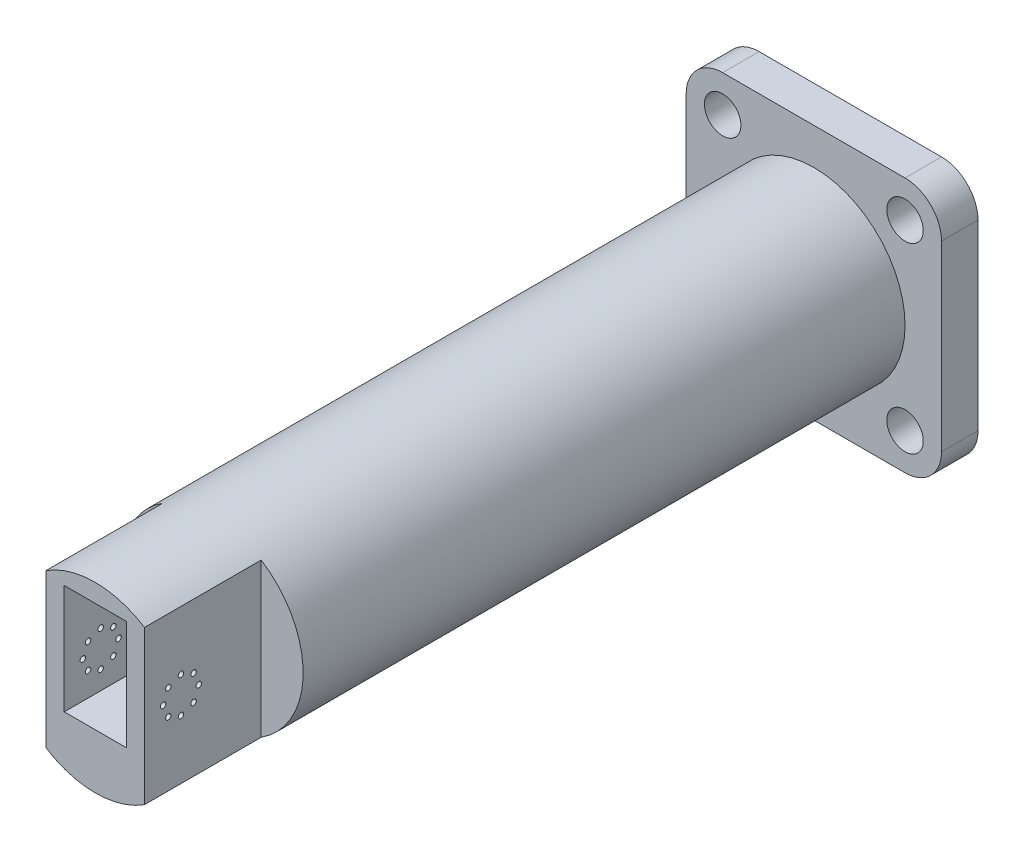
from build123d import *

# Parameters (mm, degrees)
CROQUIS1_W                 = 42
CROQUIS1_H                 = 68
CROQUIS1_W_2               = 34
CROQUIS1_H_2               = 60
SALIENTE_EXTRUIR1_DEPTH    = 60
CROQUIS2_R                 = 1.5
CORTAR_EXTRUIR1_DEPTH      = 39
CORTAR_EXTRUIR1_DEPTH_BACK = 5
CROQUIS3_W                 = 42
CROQUIS3_H                 = 68
SALIENTE_EXTRUIR2_DEPTH    = 4
CROQUIS4_W                 = 64
CROQUIS4_H                 = 20
SALIENTE_EXTRUIR3_DEPTH    = 42
SALIENTE_EXTRUIR4_DEPTH    = 64
SALIENTE_EXTRUIR6_DEPTH    = 64
CROQUIS8_R                 = 50
SALIENTE_EXTRUIR7_DEPTH    = 350
SALIENTE_EXTRUIR8_START    = -4
SALIENTE_EXTRUIR8_DEPTH    = 64
CROQUIS11_R                = 1.5
CORTAR_EXTRUIR2_DEPTH      = 68
CORTAR_EXTRUIR2_DEPTH_BACK = 34
CROQUIS13_R                = 10
CROQUIS13_R_2              = 50
SALIENTE_EXTRUIR9_DEPTH    = 20


with BuildPart() as part:
    # Croquis1 → Saliente-Extruir1 (new body)
    with BuildSketch(Plane.XY):
        Rectangle(CROQUIS1_W, CROQUIS1_H)
        Rectangle(CROQUIS1_W_2, CROQUIS1_H_2, mode=Mode.SUBTRACT)
    extrude(amount=SALIENTE_EXTRUIR1_DEPTH)

    # Croquis2 → Cortar-Extruir1 (cut, two sides)
    with BuildSketch(Plane(origin=(-17, 0, 0), x_dir=(0, 0, -1), z_dir=(1, 0, 0))) as cortar_extruir1_sk:
        with Locations((-49.779, -10)):
            Circle(CROQUIS2_R)
        with Locations((-46.914797213, -3.085202787)):
            Circle(CROQUIS2_R)
        with Locations((-40, -0.221)):
            Circle(CROQUIS2_R)
        with Locations((-33.085202787, -3.085202787)):
            Circle(CROQUIS2_R)
        with Locations((-30.221, -10)):
            Circle(CROQUIS2_R)
        with Locations((-33.085202787, -16.914797213)):
            Circle(CROQUIS2_R)
        with Locations((-40, -19.779)):
            Circle(CROQUIS2_R)
        with Locations((-46.914797213, -16.914797213)):
            Circle(CROQUIS2_R)
    extrude(amount=CORTAR_EXTRUIR1_DEPTH, mode=Mode.SUBTRACT)
    extrude(cortar_extruir1_sk.sketch, amount=-CORTAR_EXTRUIR1_DEPTH_BACK, mode=Mode.SUBTRACT)

    # Croquis3 → Saliente-Extruir2 (add)
    with BuildSketch(Plane(origin=(0, 0, 0), x_dir=(-1, 0, 0), z_dir=(0, 0, -1))):
        Rectangle(CROQUIS3_W, CROQUIS3_H)
    extrude(amount=SALIENTE_EXTRUIR2_DEPTH)

    # Croquis4 → Saliente-Extruir3 (add)
    with BuildSketch(Plane(origin=(21, 0, 0), x_dir=(0, 0, -1), z_dir=(1, 0, 0))):
        with Locations((-28, -44)):
            Rectangle(CROQUIS4_W, CROQUIS4_H)
    extrude(amount=-SALIENTE_EXTRUIR3_DEPTH)

    # Croquis5 → Saliente-Extruir4 (add)
    with BuildSketch(Plane(origin=(0, 0, -4), x_dir=(-1, 0, 0), z_dir=(0, 0, -1))):
        with BuildLine():
            ThreePointArc((21, 34), (0, 38.754486973), (-21, 34))
            Line((-21, 34), (21, 34))
        make_face()
        with BuildLine():
            ThreePointArc((-21, -54), (0, -58.754486973), (21, -54))
            Line((21, -54), (-21, -54))
        make_face()
    extrude(amount=-SALIENTE_EXTRUIR4_DEPTH)

    # Croquis6 → Saliente-Extruir6 (add)
    with BuildSketch(Plane(origin=(0, 0, -4), x_dir=(-1, 0, 0), z_dir=(0, 0, -1))):
        with BuildLine():
            Line((-21, 34), (21, 34))
            Line((21, 34), (21, 35.376205218))
            ThreePointArc((21, 35.376205218), (0, 40), (-21, 35.376205218))
            Line((-21, 35.376205218), (-21, 34))
        make_face()
        with BuildLine():
            Line((-21, -55.376205218), (-21, -54))
            Line((-21, -54), (21, -54))
            Line((21, -54), (21, -55.376205218))
            ThreePointArc((21, -55.376205218), (0, -60), (-21, -55.376205218))
        make_face()
    extrude(amount=-SALIENTE_EXTRUIR6_DEPTH)

    # Croquis8 → Saliente-Extruir7 (add)
    with BuildSketch(Plane(origin=(0, 0, -4), x_dir=(-1, 0, 0), z_dir=(0, 0, -1))):
        with Locations((0, -10)):
            Circle(CROQUIS8_R)
    extrude(amount=SALIENTE_EXTRUIR7_DEPTH)

    # Croquis10 → Saliente-Extruir8 (add)
    with BuildSketch(Plane.XY.offset(SALIENTE_EXTRUIR8_START)):
        with BuildLine():
            Line((-21, 35.376205218), (-21, -55.376205218))
            ThreePointArc((-21, -55.376205218), (-24.056410521, -53.832512053), (-27, -52.083250825))
            Line((-27, -52.083250825), (-27, 32.083250825))
            ThreePointArc((-27, 32.083250825), (-24.056410521, 33.832512053), (-21, 35.376205218))
        make_face()
        with BuildLine():
            Line((21, 35.376205218), (21, -55.376205218))
            ThreePointArc((21, -55.376205218), (24.056410521, -53.832512053), (27, -52.083250825))
            Line((27, -52.083250825), (27, 32.083250825))
            ThreePointArc((27, 32.083250825), (24.056410521, 33.832512053), (21, 35.376205218))
        make_face()
    extrude(amount=SALIENTE_EXTRUIR8_DEPTH)

    # Croquis11 → Cortar-Extruir2 (cut, two sides)
    with BuildSketch(Plane(origin=(-17, 0, 0), x_dir=(0, 0, -1), z_dir=(1, 0, 0))) as cortar_extruir2_sk:
        with Locations((-49.779, -10)):
            Circle(CROQUIS11_R)
        with Locations((-46.914797213, -3.085202787)):
            Circle(CROQUIS11_R)
        with Locations((-40, -0.221)):
            Circle(CROQUIS11_R)
        with Locations((-33.085202787, -3.085202787)):
            Circle(CROQUIS11_R)
        with Locations((-30.221, -10)):
            Circle(CROQUIS11_R)
        with Locations((-33.085202787, -16.914797213)):
            Circle(CROQUIS11_R)
        with Locations((-40, -19.779)):
            Circle(CROQUIS11_R)
        with Locations((-46.914797213, -16.914797213)):
            Circle(CROQUIS11_R)
    extrude(amount=CORTAR_EXTRUIR2_DEPTH, mode=Mode.SUBTRACT)
    extrude(cortar_extruir2_sk.sketch, amount=-CORTAR_EXTRUIR2_DEPTH_BACK, mode=Mode.SUBTRACT)

    # Croquis13 → Saliente-Extruir9 (add)
    with BuildSketch(Plane(origin=(0, 0, -354), x_dir=(-1, 0, 0), z_dir=(0, 0, -1))):
        with BuildLine():
            Line((-50, -80), (50, -80))
            ThreePointArc((50, -80), (64.142135624, -74.142135624), (70, -60))
            Line((70, -60), (70, 40))
            ThreePointArc((70, 40), (64.142135624, 54.142135624), (50, 60))
            Line((50, 60), (-50, 60))
            ThreePointArc((-50, 60), (-64.142135624, 54.142135624), (-70, 40))
            Line((-70, 40), (-70, -60))
            ThreePointArc((-70, -60), (-64.142135624, -74.142135624), (-50, -80))
        make_face()
        with Locations((-50, 40)):
            Circle(CROQUIS13_R, mode=Mode.SUBTRACT)
        with Locations((-50, -60)):
            Circle(CROQUIS13_R, mode=Mode.SUBTRACT)
        with Locations((50, 40)):
            Circle(CROQUIS13_R, mode=Mode.SUBTRACT)
        with Locations((50, -60)):
            Circle(CROQUIS13_R, mode=Mode.SUBTRACT)
        with Locations((0, -10)):
            Circle(CROQUIS13_R_2, mode=Mode.SUBTRACT)
    extrude(amount=-SALIENTE_EXTRUIR9_DEPTH)


solid = part.part
